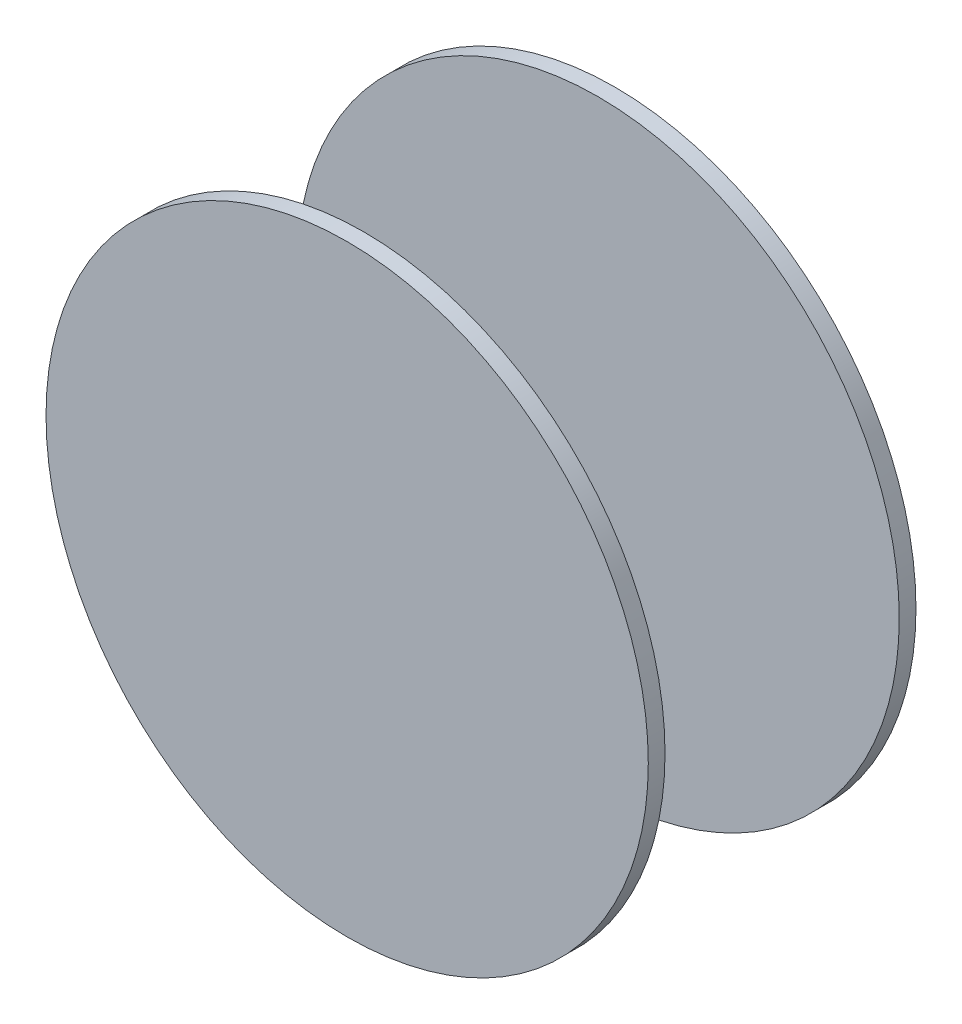
from build123d import *

# Parameters (mm, degrees)
SKETCH1_R           = 45
BOSS_EXTRUDE1_DEPTH = 20
SKETCH1_2_R         = 45
CUT_EXTRUDE1_DEPTH  = 17.5


with BuildPart() as part:
    # Sketch1 → Boss-Extrude1 (new, symmetric)
    with BuildSketch(Plane.XY):
        Circle(SKETCH1_R)
    extrude(amount=BOSS_EXTRUDE1_DEPTH, both=True)

    # Sketch1_2 → Cut-Extrude1 (cut, symmetric)
    with BuildSketch(Plane.XY):
        Circle(SKETCH1_2_R)
    extrude(amount=CUT_EXTRUDE1_DEPTH, both=True, mode=Mode.SUBTRACT)


with BuildPart() as cut_extrude1_piece_1:
    # of the separate pieces the step leaves, piece 1, a body of its own (cut_extrude1_pieces)
    add(part.part.solids().sort_by_distance((45, 0, -20))[0])


with BuildPart() as cut_extrude1_piece_2:
    # of the separate pieces the step leaves, piece 2, a body of its own (cut_extrude1_pieces)
    add(part.part.solids().sort_by_distance((45, 0, 17.5))[0])


solid = Compound([cut_extrude1_piece_1.part, cut_extrude1_piece_2.part])
